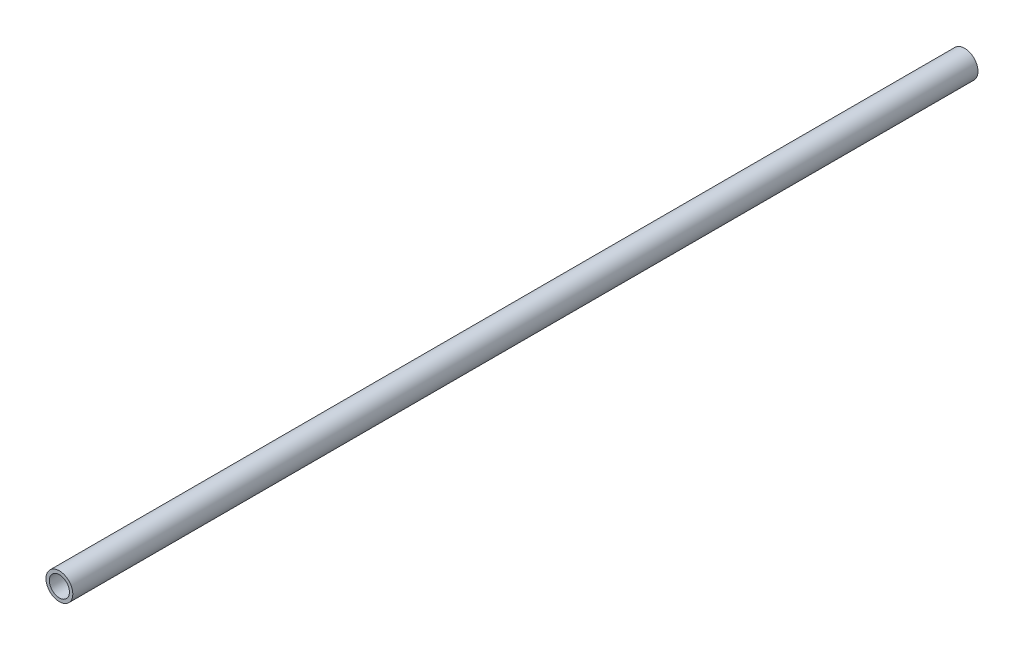
from build123d import *

# Parameters (mm, degrees)
SKETCH1_R           = 8
SKETCH1_R_2         = 6
BOSS_EXTRUDE1_DEPTH = 270


with BuildPart() as part:
    # Sketch1 → Boss-Extrude1 (new body, symmetric)
    with BuildSketch(Plane.XY):
        Circle(SKETCH1_R)
        Circle(SKETCH1_R_2, mode=Mode.SUBTRACT)
    extrude(amount=BOSS_EXTRUDE1_DEPTH, both=True)


solid = part.part
